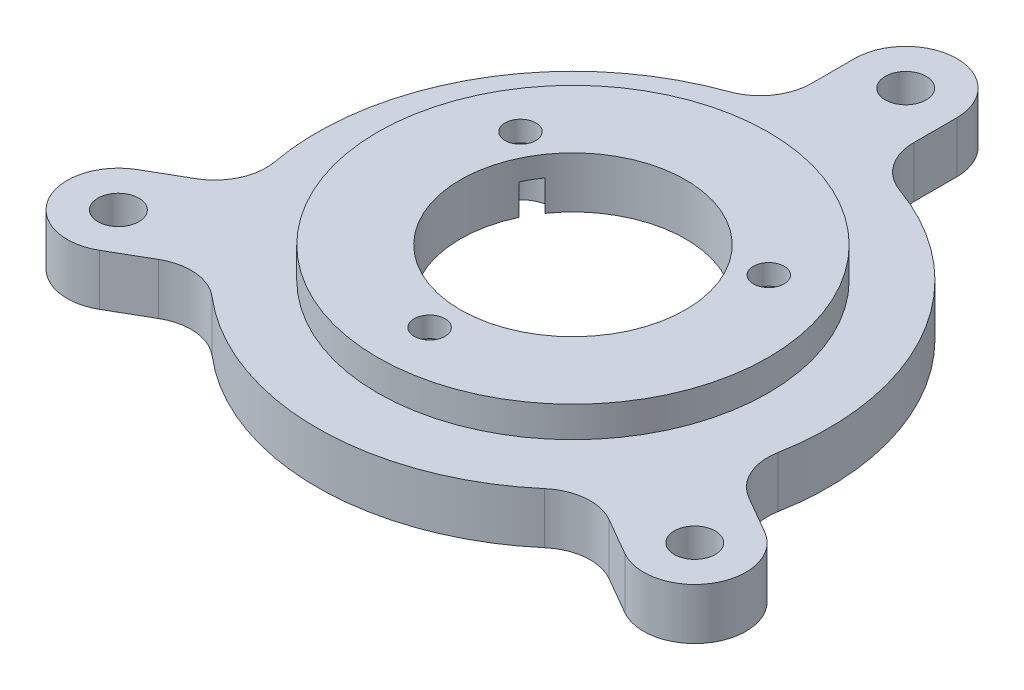
from build123d import *

# Parameters (mm, degrees)
SKETCH1_R           = 16
SKETCH1_R_2         = 2
BOSS_EXTRUDE1_DEPTH = 8
SKETCH4_R           = 16
SKETCH4_R_2         = 11
BOSS_EXTRUDE3_DEPTH = 5
SKETCH5_R           = 1.5
CUT_EXTRUDE2_DEPTH  = 9
SKETCH6_R           = 3.175
CUT_EXTRUDE3_DEPTH  = 6
SKETCH7_OUTSIDE_W   = 86.584
SKETCH7_OUTSIDE_H   = 82.792
SKETCH7_OUTSIDE_R   = 19.075
CUT_EXTRUDE4_DEPTH  = 3


with BuildPart() as part:
    # Sketch1 → Boss-Extrude1 (new body)
    with BuildSketch(Plane(origin=(0, 0, 0), x_dir=(1, 0, 0), z_dir=(0, 1, 0))):
        with BuildLine():
            Line((30.645825623, -11.919872981), (26.994897428, -9.812008605))
            ThreePointArc((26.994897428, -9.812008605), (24.953655976, -7.574039819), (24.57908119, -4.568234655))
            ThreePointArc((24.57908119, -4.568234655), (21.650635095, 12.5), (8.333333333, 23.57022604))
            ThreePointArc((8.333333333, 23.57022604), (5.917517095, 25.397519902), (5, 28.284271247))
            Line((5, 28.284271247), (5, 32.5))
            ThreePointArc((5, 32.5), (0, 37.5), (-5, 32.5))
            Line((-5, 32.5), (-5, 28.284271247))
            ThreePointArc((-5, 28.284271247), (-5.917517095, 25.397519902), (-8.333333333, 23.57022604))
            ThreePointArc((-8.333333333, 23.57022604), (-21.650635095, 12.5), (-24.57908119, -4.568234655))
            ThreePointArc((-24.57908119, -4.568234655), (-24.953655976, -7.574039819), (-26.994897428, -9.812008605))
            Line((-26.994897428, -9.812008605), (-30.645825623, -11.919872981))
            ThreePointArc((-30.645825623, -11.919872981), (-32.475952642, -18.75), (-25.645825623, -20.580127019))
            Line((-25.645825623, -20.580127019), (-21.994897428, -18.472262643))
            ThreePointArc((-21.994897428, -18.472262643), (-19.03613888, -17.823480083), (-16.245747857, -19.001991385))
            ThreePointArc((-16.245747857, -19.001991385), (0, -25), (16.245747857, -19.001991385))
            ThreePointArc((16.245747857, -19.001991385), (19.03613888, -17.823480083), (21.994897428, -18.472262643))
            Line((21.994897428, -18.472262643), (25.645825623, -20.580127019))
            ThreePointArc((25.645825623, -20.580127019), (32.475952642, -18.75), (30.645825623, -11.919872981))
        make_face()
        Circle(SKETCH1_R, mode=Mode.SUBTRACT)
        with Locations((0, 32.5)):
            Circle(SKETCH1_R_2, mode=Mode.SUBTRACT)
        with Locations((-28.145825623, -16.25)):
            Circle(SKETCH1_R_2, mode=Mode.SUBTRACT)
        with Locations((28.145825623, -16.25)):
            Circle(SKETCH1_R_2, mode=Mode.SUBTRACT)
    extrude(amount=BOSS_EXTRUDE1_DEPTH)

    # Sketch4 → Boss-Extrude3 (add)
    with BuildSketch(Plane(origin=(0, 8, 0), x_dir=(1, 0, 0), z_dir=(0, 1, 0))):
        Circle(SKETCH4_R)
        Circle(SKETCH4_R_2, mode=Mode.SUBTRACT)
    extrude(amount=-BOSS_EXTRUDE3_DEPTH)

    # Sketch5 → Cut-Extrude2 (cut, through all)
    with BuildSketch(Plane(origin=(0, 8, 0), x_dir=(1, 0, 0), z_dir=(0, 1, 0))):
        with Locations((0, -14)):
            Circle(SKETCH5_R)
        with Locations((-12.124355653, 7)):
            Circle(SKETCH5_R)
        with Locations((12.124355653, 7)):
            Circle(SKETCH5_R)
    extrude(amount=-CUT_EXTRUDE2_DEPTH, mode=Mode.SUBTRACT)

    # Sketch6 → Cut-Extrude3 (cut)
    with BuildSketch(Plane.XZ):
        with Locations((0, 14)):
            Circle(SKETCH6_R)
        with Locations((-12.124355653, -7)):
            Circle(SKETCH6_R)
        with Locations((12.124355653, -7)):
            Circle(SKETCH6_R)
    extrude(amount=-CUT_EXTRUDE3_DEPTH, mode=Mode.SUBTRACT)

    # Sketch7 outside → Cut-Extrude4 (cut)
    with BuildSketch(Plane(origin=(0, 8, 0), x_dir=(1, 0, 0), z_dir=(0, 1, 0))):
        with Locations((0, 6.25)):
            Rectangle(SKETCH7_OUTSIDE_W, SKETCH7_OUTSIDE_H)
        Circle(SKETCH7_OUTSIDE_R, mode=Mode.SUBTRACT)
    extrude(amount=-CUT_EXTRUDE4_DEPTH, mode=Mode.SUBTRACT)


solid = part.part
